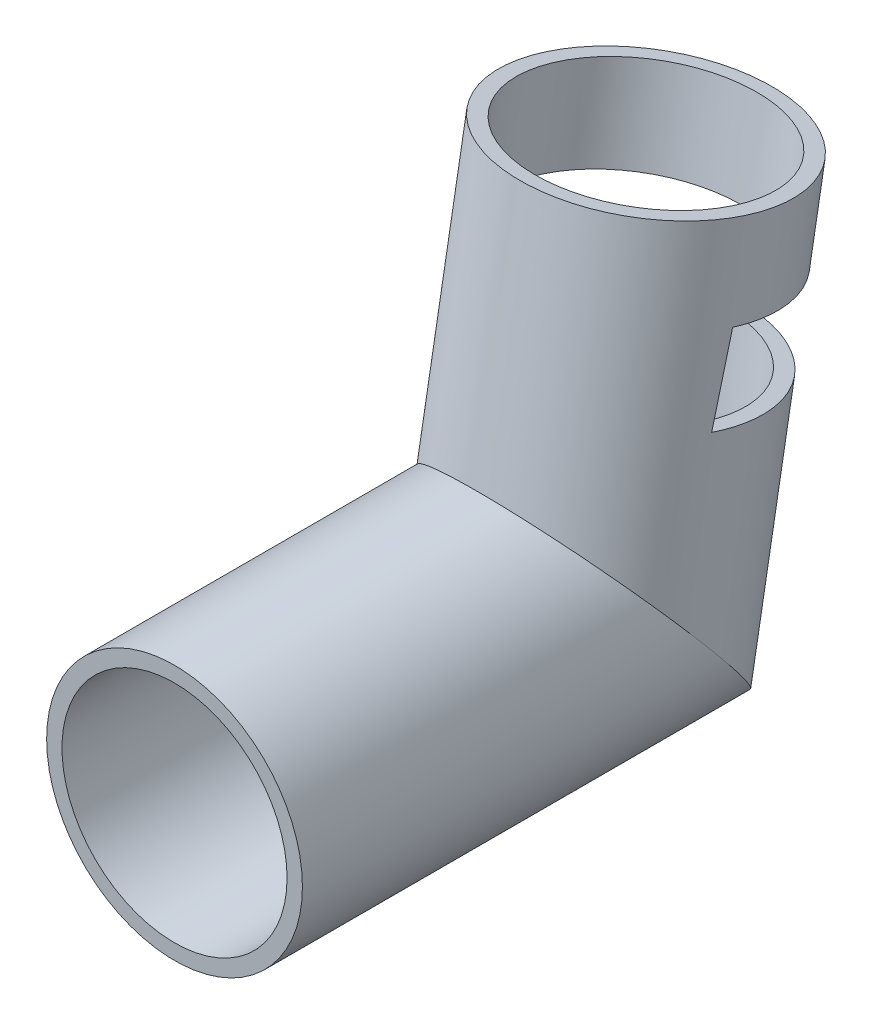
from build123d import *

# Parameters (mm, degrees)
SKETCH3_R               = 25
SKETCH3_R_2             = 22
CUT_EXTRUDE2_DEPTH      = 26
CUT_EXTRUDE2_DEPTH_BACK = 26


with BuildPart() as part:
    # Sweep1: sweep along a path in Sketch1
    with BuildLine(Plane(origin=(0, 0, 0), x_dir=(0, 0, -1), z_dir=(1, 0, 0))) as sweep1_path:
        Line((0, 0), (80, 0))
        Line((80, 0), (92.155372437, 68.936542711))
    # Sketch3 → Sweep1 (sweep)
    with BuildSketch(Plane.XY):
        Circle(SKETCH3_R)
        Circle(SKETCH3_R_2, mode=Mode.SUBTRACT)
    sweep(path=sweep1_path.line, transition=Transition.RIGHT)

    # Sketch4 → Cut-Extrude2 (cut, two sides)
    with BuildSketch(Plane(origin=(0, 0, 0), x_dir=(0, 0, -1), z_dir=(1, 0, 0))) as cut_extrude2_sk:
        Polygon((110.842308967, 30.946164041), (113.687194162, 47.080309724), (94.794337041, 50.411630176), (84.524899127, 52.222409157), (80.652201417, 36.269494553), align=None)
    extrude(amount=CUT_EXTRUDE2_DEPTH, mode=Mode.SUBTRACT)
    extrude(cut_extrude2_sk.sketch, amount=-CUT_EXTRUDE2_DEPTH_BACK, mode=Mode.SUBTRACT)


solid = part.part
